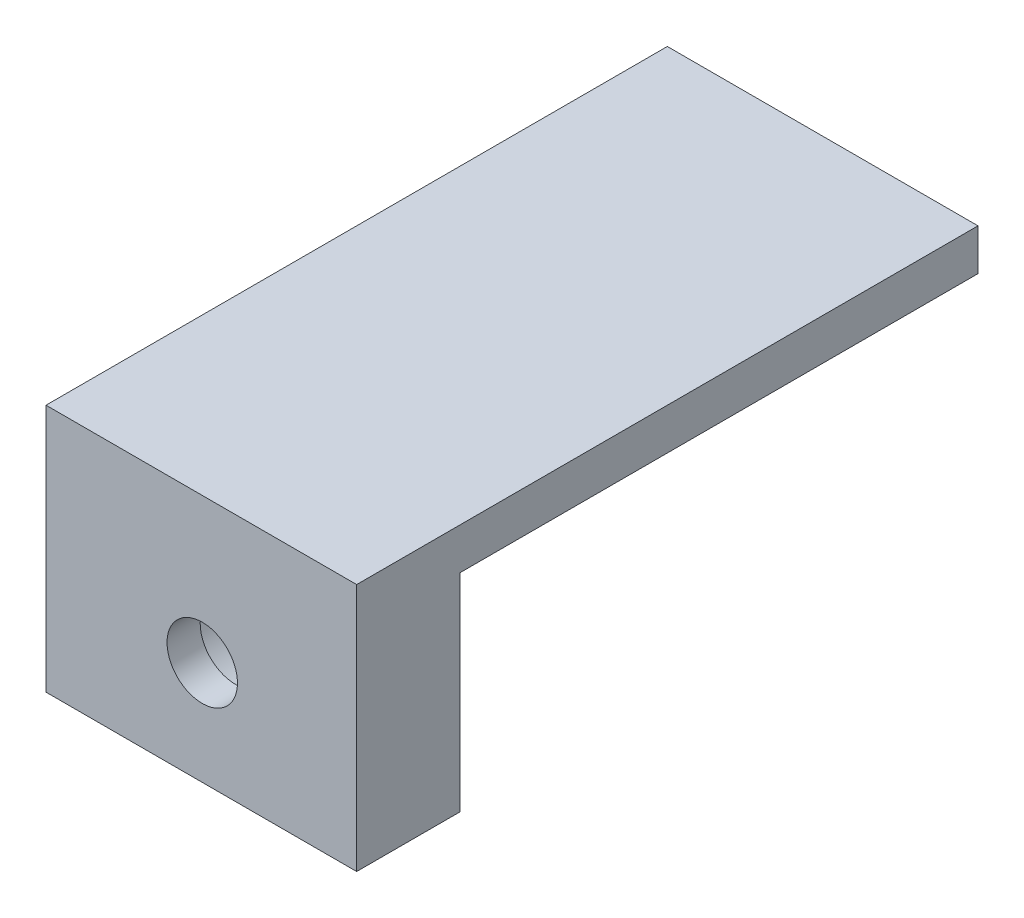
from build123d import *

# Parameters (mm, degrees)
SKETCH_1_W                   = 15
SKETCH_1_H                   = 12
EXTRUDE_1_DEPTH              = 5
SKETCH_2_W                   = 15
SKETCH_2_H                   = 2
EXTRUDE_2_DEPTH              = 25
SKETCH_6_W                   = 15
SKETCH_6_H                   = 5
CUT_EXTRUDE_2_DEPTH          = 6
SKETCH_7_W                   = 15
SKETCH_7_H                   = 5
EXTRUDE_3_DEPTH              = 5
HOLE_WIZARD_M3_1_D           = 3.4
HOLE_WIZARD_M3_1_DEPTH       = 7.5
HOLE_WIZARD_M3_1_CBORE_D     = 6.5
HOLE_WIZARD_M3_1_CBORE_DEPTH = 3.4
HOLE_WIZARD_M3_1_TIP         = 1.021463052


with BuildPart() as part:
    # 草图1 → 凸台-拉伸1 (new body)
    with BuildSketch(Plane.XY):
        with Locations((7.5, 6)):
            Rectangle(SKETCH_1_W, SKETCH_1_H)
    extrude(amount=EXTRUDE_1_DEPTH)

    # 草图2 → 凸台-拉伸2 (add)
    with BuildSketch(Plane(origin=(0, 0, 0), x_dir=(-1, 0, 0), z_dir=(0, 0, -1))):
        with Locations((-7.5, 6)):
            Rectangle(SKETCH_2_W, SKETCH_2_H)
    extrude(amount=EXTRUDE_2_DEPTH)

    # 草图6 → 切除-拉伸2 (cut, through all)
    with BuildSketch(Plane(origin=(0, 0, 0), x_dir=(-1, 0, 0), z_dir=(0, 0, -1))):
        with Locations((-7.5, 9.5)):
            Rectangle(SKETCH_6_W, SKETCH_6_H)
    extrude(amount=-CUT_EXTRUDE_2_DEPTH, mode=Mode.SUBTRACT)

    # 草图7 → 凸台-拉伸3 (add)
    with BuildSketch(Plane.XZ):
        with Locations((7.5, 2.5)):
            Rectangle(SKETCH_7_W, SKETCH_7_H)
    extrude(amount=EXTRUDE_3_DEPTH)

    # M3 六角凹头螺钉的柱形沉头孔1
    with Locations(Plane(origin=(0, 0, 0), x_dir=(-1, 0, 0), z_dir=(0, 0, -1))):
        with Locations((-7.544327116, 0)):
            CounterBoreHole(HOLE_WIZARD_M3_1_D / 2, HOLE_WIZARD_M3_1_CBORE_D / 2, HOLE_WIZARD_M3_1_CBORE_DEPTH, depth=HOLE_WIZARD_M3_1_DEPTH)
            with Locations((0, 0, -(HOLE_WIZARD_M3_1_DEPTH + HOLE_WIZARD_M3_1_TIP / 2))):  # 118° drill point
                Cone(0, HOLE_WIZARD_M3_1_D / 2, HOLE_WIZARD_M3_1_TIP, mode=Mode.SUBTRACT)


solid = part.part
